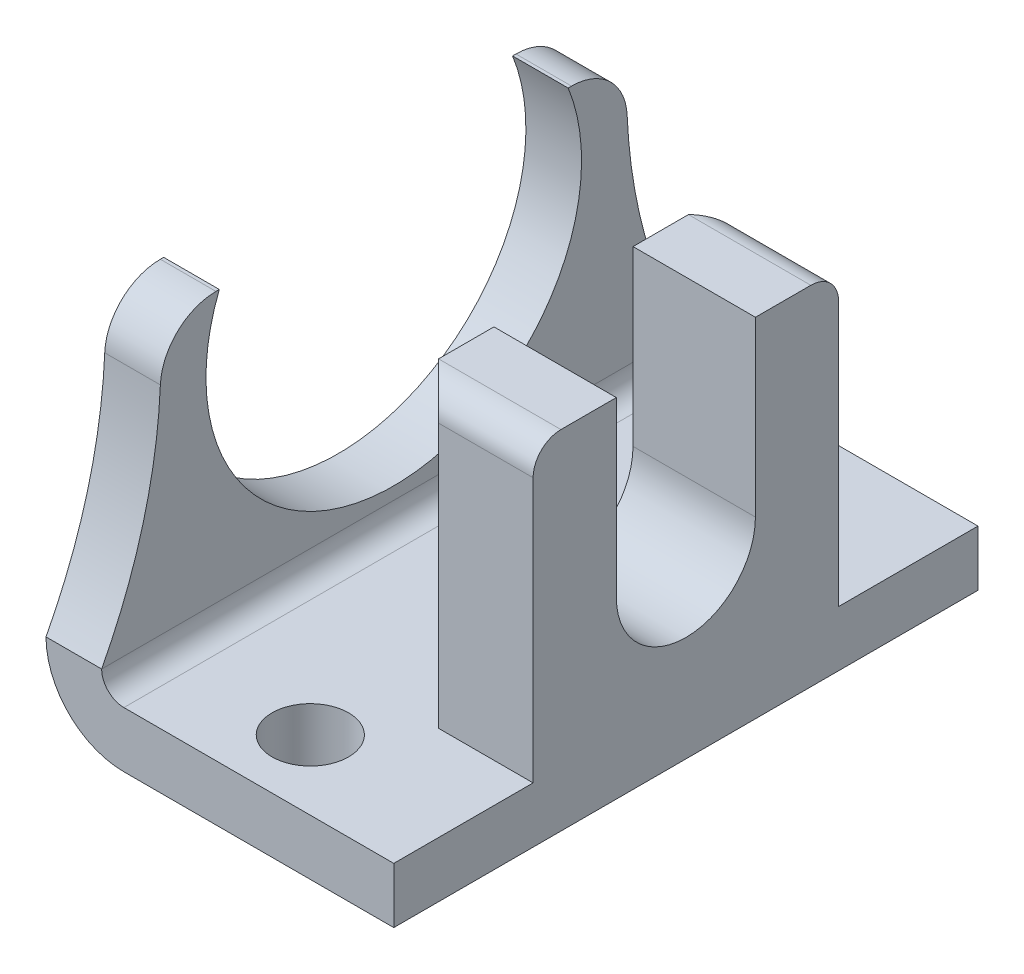
from build123d import *

# Parameters (mm, degrees)
SKIZZE1_W                            = 42
SKIZZE1_H                            = 25
AUFSATZ_LINEAR_AUSTRAGEN1_DEPTH      = 25
SKIZZE2_W                            = 21
SKIZZE2_H                            = 21
SCHNITT_LINEAR_AUSTRAGEN1_DEPTH      = 43
SCHNITT_LINEAR_AUSTRAGEN2_DEPTH      = 5
SKIZZE4_W                            = 8.8
SKIZZE4_H                            = 21.963947762
AUFSATZ_LINEAR_AUSTRAGEN2_DEPTH      = 21
SCHNITT_LINEAR_AUSTRAGEN3_REACH      = 27
SCHNITT_LINEAR_AUSTRAGEN4_DEPTH      = 5
DURCHGANGSLOCH_F_R_M241_D            = 27
DURCHGANGSLOCH_F_R_M241_DEPTH        = 4
F_5_5_5_5_DURCHMESSER_BOHRUNG1_D     = 5.5
F_5_5_5_5_DURCHMESSER_BOHRUNG1_DEPTH = 25
FASE1_SIZE                           = 2
VERRUNDUNG1_R                        = 1.6
VERRUNDUNG2_R                        = 2
VERRUNDUNG3_R                        = 4
VERRUNDUNG4_R                        = 5.6


with BuildPart() as part:
    # Skizze1 → Aufsatz-Linear austragen1 (new body)
    with BuildSketch(Plane(origin=(25, 0, 0), x_dir=(0, 0, -1), z_dir=(1, 0, 0))):
        with Locations((0, 12.5)):
            Rectangle(SKIZZE1_W, SKIZZE1_H)
    extrude(amount=-AUFSATZ_LINEAR_AUSTRAGEN1_DEPTH)

    # Skizze2 → Schnitt-Linear austragen1 (cut, through all)
    with BuildSketch(Plane.XY.offset(21)):
        with Locations((14.5, 14.5)):
            Rectangle(SKIZZE2_W, SKIZZE2_H)
    extrude(amount=-SCHNITT_LINEAR_AUSTRAGEN1_DEPTH, mode=Mode.SUBTRACT)

    # Skizze3 → Schnitt-Linear austragen2 (cut, through all)
    with BuildSketch(Plane(origin=(4, 0, 0), x_dir=(0, 0, -1), z_dir=(1, 0, 0))):
        with BuildLine():
            Line((-21, 25), (-21, 5.6))
            ThreePointArc((-21, 5.6), (-17.5737339, 15.012569088), (-16.807587704, 25))
            Line((-16.807587704, 25), (-21, 25))
        make_face()
    extrude(amount=-SCHNITT_LINEAR_AUSTRAGEN2_DEPTH, mode=Mode.SUBTRACT)

    # Skizze4 → Aufsatz-Linear austragen2 (add)
    with BuildSketch(Plane(origin=(0, 4, 0), x_dir=(-1, 0, 0), z_dir=(0, 1, 0))):
        with Locations((-20.6, 0)):
            Rectangle(SKIZZE4_W, SKIZZE4_H)
    extrude(amount=AUFSATZ_LINEAR_AUSTRAGEN2_DEPTH)

    # Skizze5 → Schnitt-Linear austragen3 (cut, up to next)
    with BuildSketch(Plane(origin=(25, 0, 0), x_dir=(0, 0, -1), z_dir=(1, 0, 0)), mode=Mode.PRIVATE) as schnitt_linear_austragen3_sk1:
        with BuildLine():
            Line((5, 25), (-5, 25))
            Line((-5, 25), (-5, 12.560423389))
            ThreePointArc((-5, 12.560423389), (0, 7.560423389), (5, 12.560423389))
            Line((5, 12.560423389), (5, 25))
        make_face()
    schnitt_linear_austragen3_tool1 = extrude(schnitt_linear_austragen3_sk1.sketch, amount=-SCHNITT_LINEAR_AUSTRAGEN3_REACH, mode=Mode.PRIVATE) & part.part
    add(schnitt_linear_austragen3_tool1.solids().sort_by_distance((25, 16.778669, 0))[0], mode=Mode.SUBTRACT)

    # Skizze6 → Schnitt-Linear austragen4 (cut, through all)
    with BuildSketch(Plane(origin=(4, 0, 0), x_dir=(0, 0, -1), z_dir=(1, 0, 0))):
        with BuildLine():
            Line((21, 25), (16.807587704, 25))
            ThreePointArc((16.807587704, 25), (17.5737339, 15.012569088), (21, 5.6))
            Line((21, 5.6), (21, 25))
        make_face()
    extrude(amount=-SCHNITT_LINEAR_AUSTRAGEN4_DEPTH, mode=Mode.SUBTRACT)

    # Durchgangsloch für M241
    with Locations(Plane(origin=(4, 0, 0), x_dir=(0, 0, -1), z_dir=(1, 0, 0))):
        with Locations((0, 20)):
            Hole(DURCHGANGSLOCH_F_R_M241_D / 2, depth=DURCHGANGSLOCH_F_R_M241_DEPTH)

    # Ø5.5 (5.5) Durchmesser Bohrung1
    with Locations(Plane(origin=(0, 0, 0), x_dir=(-1, 0, 0), z_dir=(0, -1, 0))):
        with Locations((-14, -16), (-14, 16)):
            Hole(F_5_5_5_5_DURCHMESSER_BOHRUNG1_D / 2, depth=F_5_5_5_5_DURCHMESSER_BOHRUNG1_DEPTH)

    # Fase1
    fase1_edges = [part.edges().sort_by_distance(p)[0] for p in [
        (16.2, 14.5, -10.981973881),
        (16.2, 14.5, 10.981973881),
    ]]
    chamfer(fase1_edges, length=FASE1_SIZE)

    # Verrundung1
    verrundung1_edges = [part.edges().sort_by_distance(p)[0] for p in [
        (4, 4, 0),
    ]]
    fillet(verrundung1_edges, radius=VERRUNDUNG1_R)

    # Verrundung2
    verrundung2_edges = [part.edges().sort_by_distance(p)[0] for p in [
        (21.6, 25, 10.981973881),
        (21.6, 25, -10.981973881),
    ]]
    fillet(verrundung2_edges, radius=VERRUNDUNG2_R)

    # Verrundung3
    verrundung3_edges = [part.edges().sort_by_distance(p)[0] for p in [
        (2, 25, 16.807587704),
        (2, 25, -16.807587704),
    ]]
    fillet(verrundung3_edges, radius=VERRUNDUNG3_R)

    # Verrundung4
    verrundung4_edges = [part.edges().sort_by_distance(p)[0] for p in [
        (0, 0, 0),
    ]]
    fillet(verrundung4_edges, radius=VERRUNDUNG4_R)


solid = part.part
